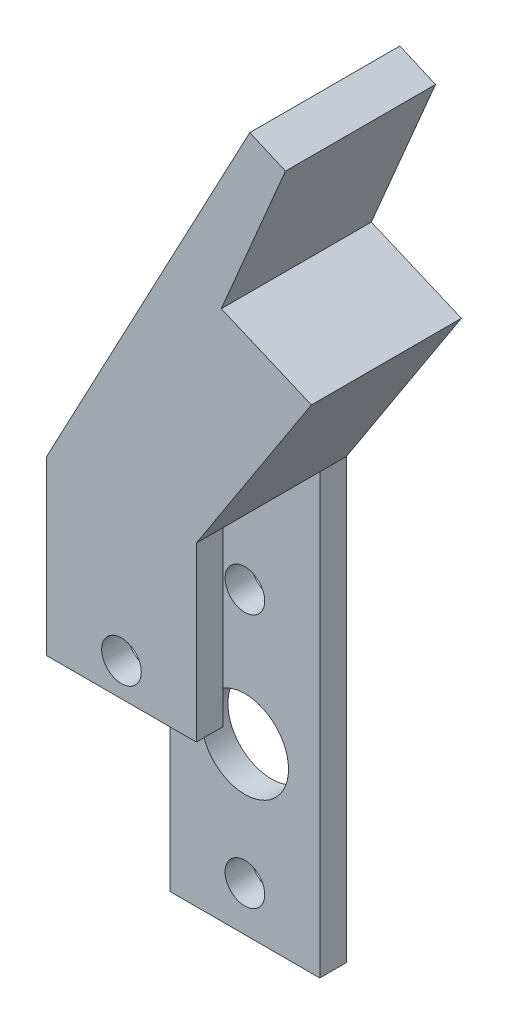
from build123d import *

# Parameters (mm, degrees)
BOSS_EXTRUDE1_DEPTH = 14.3256
SKETCH2_R           = 1.8923
SKETCH2_R_2         = 4.1656
CUT_EXTRUDE1_DEPTH  = 14.3256
SKETCH3_W           = 9.2456
SKETCH3_H           = 41.8592
CUT_EXTRUDE2_DEPTH  = 14.3256
SKETCH4_W           = 2.54
SKETCH4_H           = 25.4
CUT_EXTRUDE3_DEPTH  = 14.3256


with BuildPart() as part:
    # Sketch1 → Boss-Extrude1 (new body)
    with BuildSketch(Plane.XY):
        Polygon((-110.51464309, 1.262410177), (-96.21444309, 1.262410177), (-96.21444309, 43.121610177), (-85.230380887, 60.035582724), (-93.834523853, 63.687824728), (-87.701139183, 78.137173513), (-91.11335518, 79.61012581), (-110.51464309, 43.121610177), align=None)
    extrude(amount=BOSS_EXTRUDE1_DEPTH)

    # Sketch2 → Cut-Extrude1 (cut)
    with BuildSketch(Plane.XY.offset(14.3256)):
        with Locations((-103.36454309, 5.529610177)):
            Circle(SKETCH2_R)
        with Locations((-103.36454309, 17.035810177)):
            Circle(SKETCH2_R_2)
        with Locations((-103.36454309, 29.812010177)):
            Circle(SKETCH2_R)
    extrude(amount=-CUT_EXTRUDE1_DEPTH, mode=Mode.SUBTRACT)

    # Sketch3 → Cut-Extrude2 (cut)
    with BuildSketch(Plane(origin=(-96.21444309, 0, 0), x_dir=(0, 0, -1), z_dir=(1, 0, 0))):
        with Locations((-7.1628, 22.192010177)):
            Rectangle(SKETCH3_W, SKETCH3_H)
    extrude(amount=-CUT_EXTRUDE2_DEPTH, mode=Mode.SUBTRACT)

    # Sketch4 → Cut-Extrude3 (cut)
    with BuildSketch(Plane(origin=(-96.21444309, 0, 0), x_dir=(0, 0, -1), z_dir=(1, 0, 0))):
        with Locations((-13.0556, 13.962410177)):
            Rectangle(SKETCH4_W, SKETCH4_H)
    extrude(amount=-CUT_EXTRUDE3_DEPTH, mode=Mode.SUBTRACT)


solid = part.part
